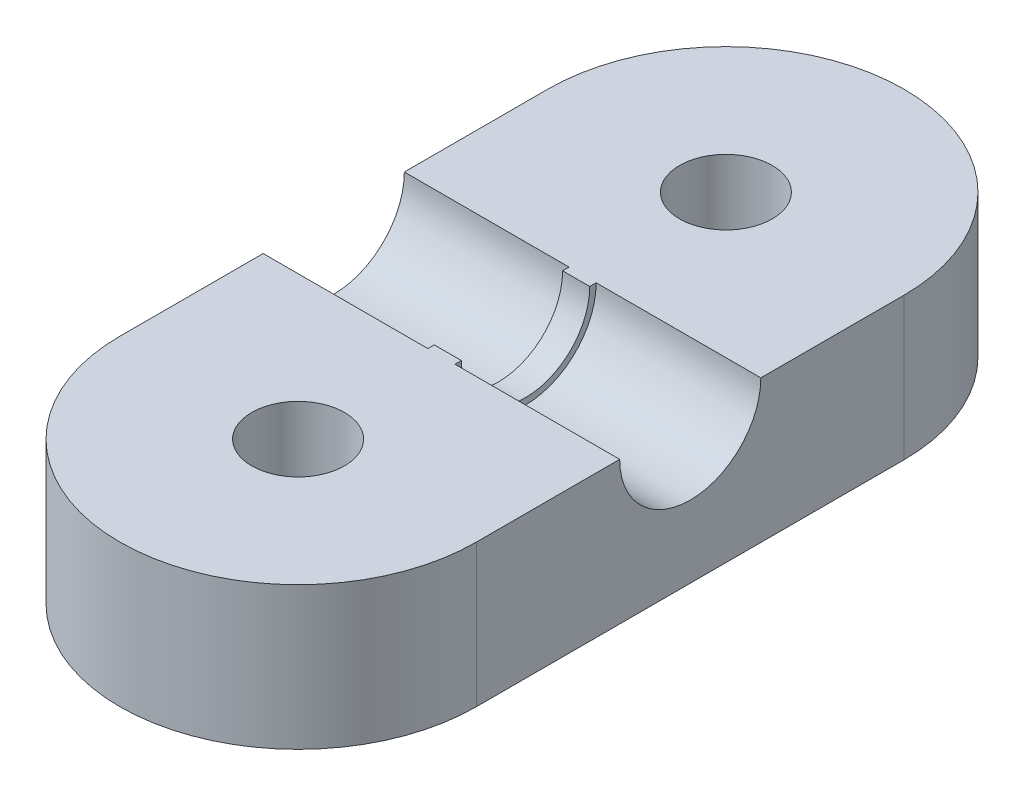
from build123d import *

# Parameters (mm, degrees)
SKETCH1_R           = 12.5
SKETCH1_R_2         = 3.25
BOSS_EXTRUDE1_DEPTH = 10
CUT_EXTRUDE1_REACH  = 27
SKETCH2_R           = 4.95
BOSS_EXTRUDE2_DEPTH = 0.95


with BuildPart() as part:
    # Sketch1 → Boss-Extrude1 (new body)
    with BuildSketch(Plane(origin=(0, 0, 0), x_dir=(1, 0, 0), z_dir=(0, 1, 0))):
        with BuildLine():
            ThreePointArc((12.5, 15), (0, 2.5), (-12.5, 15))
            Line((-12.5, 15), (-12.5, -14.999999966))
            ThreePointArc((-12.5, -14.999999966), (1.7e-08, -2.5), (12.5, -15))
            Line((12.5, -15), (12.5, 15))
        make_face()
        with Locations((0, 15)):
            Circle(SKETCH1_R)
        with Locations((0, 15)):
            Circle(SKETCH1_R_2, mode=Mode.SUBTRACT)
        with Locations((0, -15)):
            Circle(SKETCH1_R)
        with Locations((0, -15)):
            Circle(SKETCH1_R_2, mode=Mode.SUBTRACT)
    extrude(amount=BOSS_EXTRUDE1_DEPTH)

    # Sketch2 → Cut-Extrude1 (cut, up to next)
    with BuildSketch(Plane(origin=(12.5, 0, 0), x_dir=(0, 0, -1), z_dir=(1, 0, 0)), mode=Mode.PRIVATE) as cut_extrude1_sk1:
        with Locations((0, 10)):
            Circle(SKETCH2_R)
    cut_extrude1_tool1 = extrude(cut_extrude1_sk1.sketch, amount=-CUT_EXTRUDE1_REACH, mode=Mode.PRIVATE) & part.part
    add(cut_extrude1_tool1.solids().sort_by_distance((12.5, 10, 0))[0], mode=Mode.SUBTRACT)

    # Sketch3 → Boss-Extrude2 (add, symmetric)
    with BuildSketch(Plane(origin=(0, 0, 0), x_dir=(0, 0, -1), z_dir=(1, 0, 0))):
        with BuildLine():
            Line((4.95, 10), (4.5, 10))
            ThreePointArc((4.5, 10), (0, 5.5), (-4.5, 10))
            Line((-4.5, 10), (-4.95, 10))
            ThreePointArc((-4.95, 10), (0, 5.05), (4.95, 10))
        make_face()
    extrude(amount=BOSS_EXTRUDE2_DEPTH, both=True)


solid = part.part
